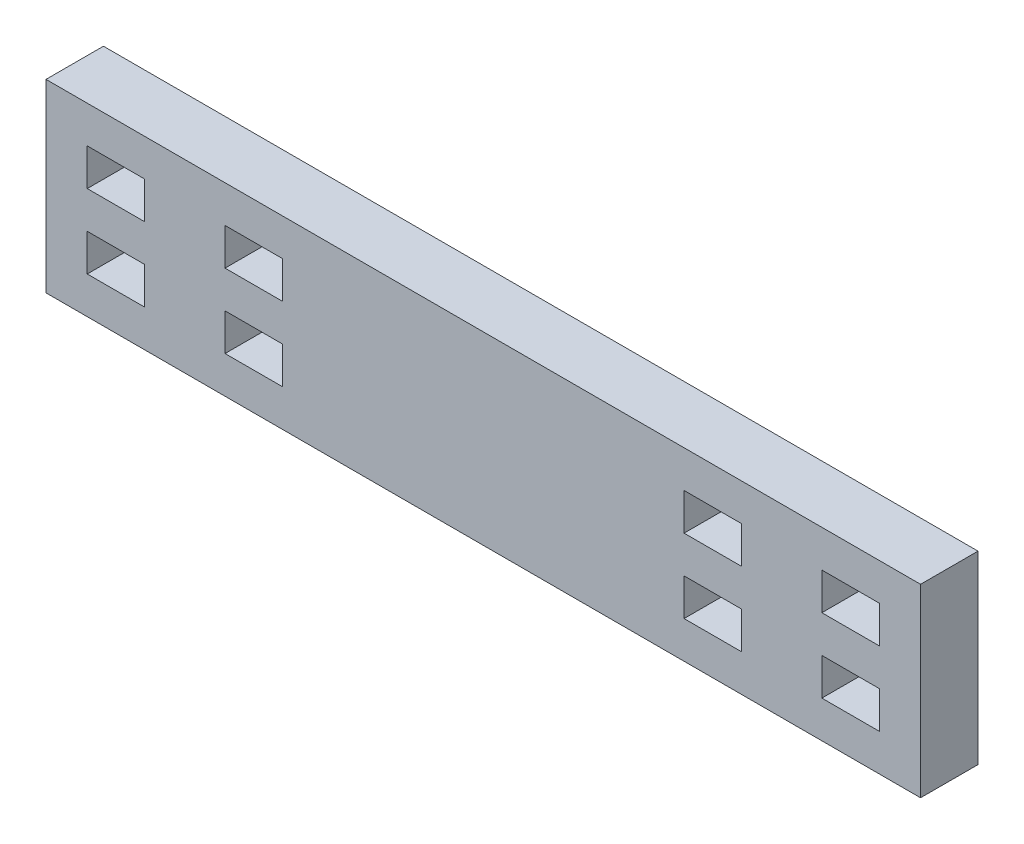
from build123d import *

# Parameters (mm, degrees)
SKETCH1_W           = 78.4
SKETCH1_H           = 16.577
BOSS_EXTRUDE1_DEPTH = 5.15
SKETCH2_W           = 5.15
SKETCH2_H           = 3.3154
CUT_EXTRUDE1_DEPTH  = 6.15


with BuildPart() as part:
    # Sketch1 → Boss-Extrude1 (new body)
    with BuildSketch(Plane.XY):
        with Locations((39.2, 8.2885)):
            Rectangle(SKETCH1_W, SKETCH1_H)
    extrude(amount=BOSS_EXTRUDE1_DEPTH)

    # Sketch2 → Cut-Extrude1 (cut, through all)
    with BuildSketch(Plane.XY.offset(5.15)):
        with Locations((6.271959232, 11.6039)):
            Rectangle(SKETCH2_W, SKETCH2_H)
        with Locations((6.271959232, 4.9731)):
            Rectangle(SKETCH2_W, SKETCH2_H)
        with Locations((18.625, 11.6039)):
            Rectangle(SKETCH2_W, SKETCH2_H)
        with Locations((18.625, 4.9731)):
            Rectangle(SKETCH2_W, SKETCH2_H)
        with Locations((59.775, 4.9731)):
            Rectangle(SKETCH2_W, SKETCH2_H)
        with Locations((59.775, 11.6039)):
            Rectangle(SKETCH2_W, SKETCH2_H)
        with Locations((72.128040768, 4.9731)):
            Rectangle(SKETCH2_W, SKETCH2_H)
        with Locations((72.128040768, 11.6039)):
            Rectangle(SKETCH2_W, SKETCH2_H)
    extrude(amount=-CUT_EXTRUDE1_DEPTH, mode=Mode.SUBTRACT)


solid = part.part
